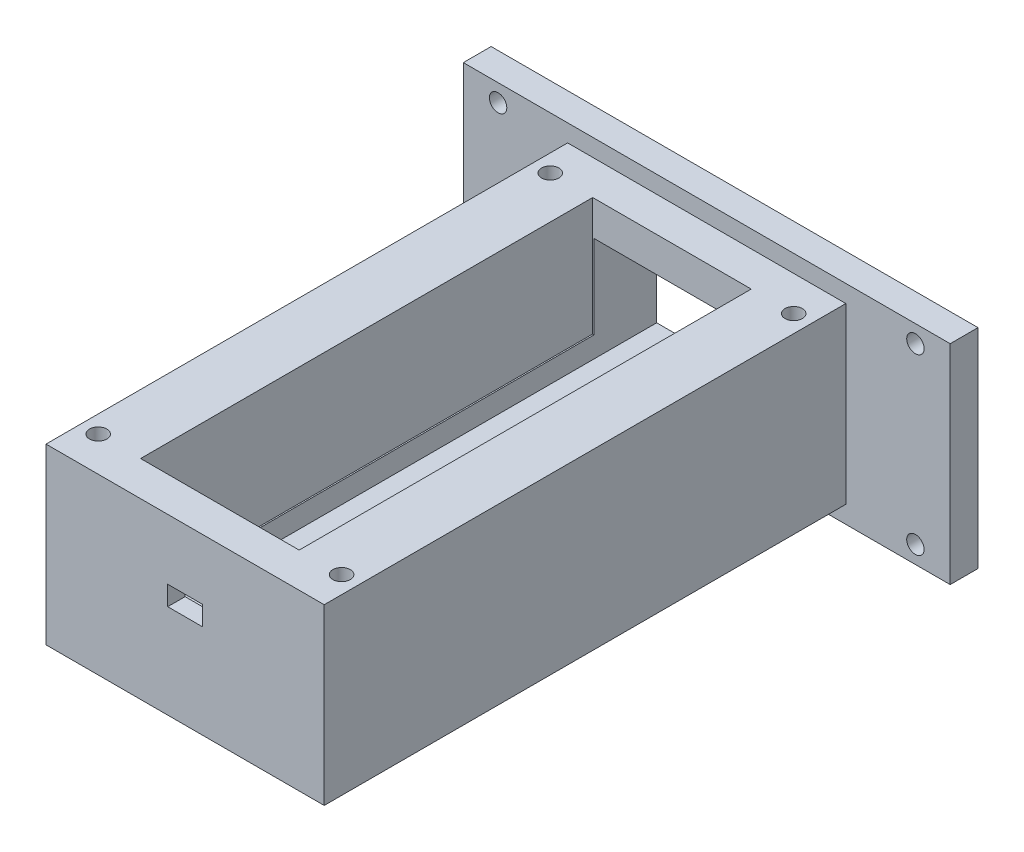
from build123d import *

# Parameters (mm, degrees)
SKETCH2_W           = 70
SKETCH2_H           = 30
BOSS_EXTRUDE1_DEPTH = 4
SKETCH4_W           = 40
SKETCH4_H           = 25
BOSS_EXTRUDE7_DEPTH = 75
SKETCH6_W           = 22.4
SKETCH6_H           = 15
CUT_EXTRUDE13_DEPTH = 76.5
SKETCH8_W           = 22.8
SKETCH8_H           = 65
CUT_EXTRUDE14_DEPTH = 17
SKETCH9_R           = 1.25
CUT_EXTRUDE15_DEPTH = 28.5
SKETCH10_R          = 2.9
CUT_EXTRUDE18_DEPTH = 10
SKETCH11_W          = 5
SKETCH11_H          = 2.8
CUT_EXTRUDE17_DEPTH = 10
SKETCH12_R          = 1.25
CUT_EXTRUDE20_DEPTH = 10


with BuildPart() as part:
    # Sketch2 → Boss-Extrude1 (new body)
    with BuildSketch(Plane.XY):
        with Locations((11.210953405, 2.8125)):
            Rectangle(SKETCH2_W, SKETCH2_H)
    extrude(amount=BOSS_EXTRUDE1_DEPTH)

    # Sketch4 → Boss-Extrude7 (add)
    with BuildSketch(Plane.XY.offset(4)):
        with Locations((11.210953405, 2.8125)):
            Rectangle(SKETCH4_W, SKETCH4_H)
    extrude(amount=BOSS_EXTRUDE7_DEPTH)

    # Sketch6 → Cut-Extrude13 (cut)
    with BuildSketch(Plane(origin=(0, 0, 0), x_dir=(-1, 0, 0), z_dir=(0, 0, -1))):
        with Locations((-11.210953405, 2.8125)):
            Rectangle(SKETCH6_W, SKETCH6_H)
    extrude(amount=-CUT_EXTRUDE13_DEPTH, mode=Mode.SUBTRACT)

    # Sketch8 → Cut-Extrude14 (cut)
    with BuildSketch(Plane(origin=(0, 15.3125, 0), x_dir=(1, 0, 0), z_dir=(0, 1, 0))):
        with Locations((11.210953405, -41.5)):
            Rectangle(SKETCH8_W, SKETCH8_H)
    extrude(amount=-CUT_EXTRUDE14_DEPTH, mode=Mode.SUBTRACT)

    # Sketch9 → Cut-Extrude15 (cut, through all)
    with BuildSketch(Plane(origin=(0, 15.3125, 0), x_dir=(1, 0, 0), z_dir=(0, 1, 0))):
        with Locations((-6.289046595, -9)):
            Circle(SKETCH9_R)
        with Locations((28.710953405, -9)):
            Circle(SKETCH9_R)
        with Locations((-6.289046595, -74)):
            Circle(SKETCH9_R)
        with Locations((28.710953405, -74)):
            Circle(SKETCH9_R)
    extrude(amount=-CUT_EXTRUDE15_DEPTH, mode=Mode.SUBTRACT)

    # Sketch10 → Cut-Extrude18 (cut)
    with BuildSketch(Plane.XZ.offset(9.6875)):
        with Locations((11.210953405, 59)):
            Circle(SKETCH10_R)
    extrude(amount=-CUT_EXTRUDE18_DEPTH, mode=Mode.SUBTRACT)

    # Sketch11 → Cut-Extrude17 (cut)
    with BuildSketch(Plane.XY.offset(79)):
        with Locations((11.210953405, 5.2125)):
            Rectangle(SKETCH11_W, SKETCH11_H)
    extrude(amount=-CUT_EXTRUDE17_DEPTH, mode=Mode.SUBTRACT)

    # Sketch12 → Cut-Extrude20 (cut)
    with BuildSketch(Plane(origin=(0, 0, 0), x_dir=(-1, 0, 0), z_dir=(0, 0, -1))):
        with Locations((-41.210953405, 15.3125)):
            Circle(SKETCH12_R)
        with Locations((18.789046595, 15.3125)):
            Circle(SKETCH12_R)
        with Locations((18.789046595, -9.6875)):
            Circle(SKETCH12_R)
        with Locations((-41.210953405, -9.6875)):
            Circle(SKETCH12_R)
    extrude(amount=-CUT_EXTRUDE20_DEPTH, mode=Mode.SUBTRACT)


solid = part.part
